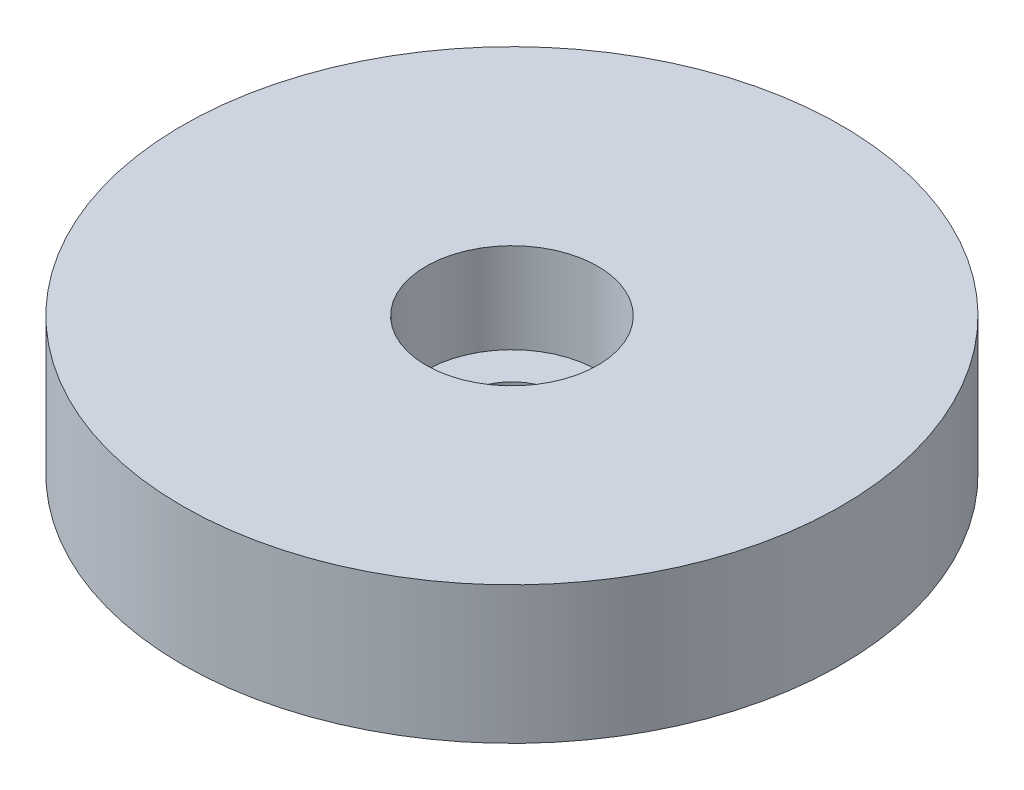
from build123d import *

# Parameters (mm, degrees)
SKETCH1_R                                      = 15.24
EXTRUDE1_DEPTH                                 = 6.35
CBORE_FOR_8_SOCKET_HEAD_CAP_SCREW1_D           = 4.3053
CBORE_FOR_8_SOCKET_HEAD_CAP_SCREW1_DEPTH       = 6.35
CBORE_FOR_8_SOCKET_HEAD_CAP_SCREW1_CBORE_D     = 7.9375
CBORE_FOR_8_SOCKET_HEAD_CAP_SCREW1_CBORE_DEPTH = 4.1656


with BuildPart() as part:
    # Sketch1 → Extrude1 (new body)
    with BuildSketch(Plane(origin=(0, 0, 0), x_dir=(1, 0, 0), z_dir=(0, 1, 0))):
        with Locations(Location((0, 0, 0), (0, 0, 270))):  # turned: the seam where the file's is
            Circle(SKETCH1_R)
    extrude(amount=EXTRUDE1_DEPTH)

    # CBORE for #8 Socket Head Cap Screw1
    with Locations(Plane.ZX.offset(6.35)):
        with Locations((0, 0)):
            CounterBoreHole(CBORE_FOR_8_SOCKET_HEAD_CAP_SCREW1_D / 2, CBORE_FOR_8_SOCKET_HEAD_CAP_SCREW1_CBORE_D / 2, CBORE_FOR_8_SOCKET_HEAD_CAP_SCREW1_CBORE_DEPTH, depth=CBORE_FOR_8_SOCKET_HEAD_CAP_SCREW1_DEPTH)


solid = part.part
